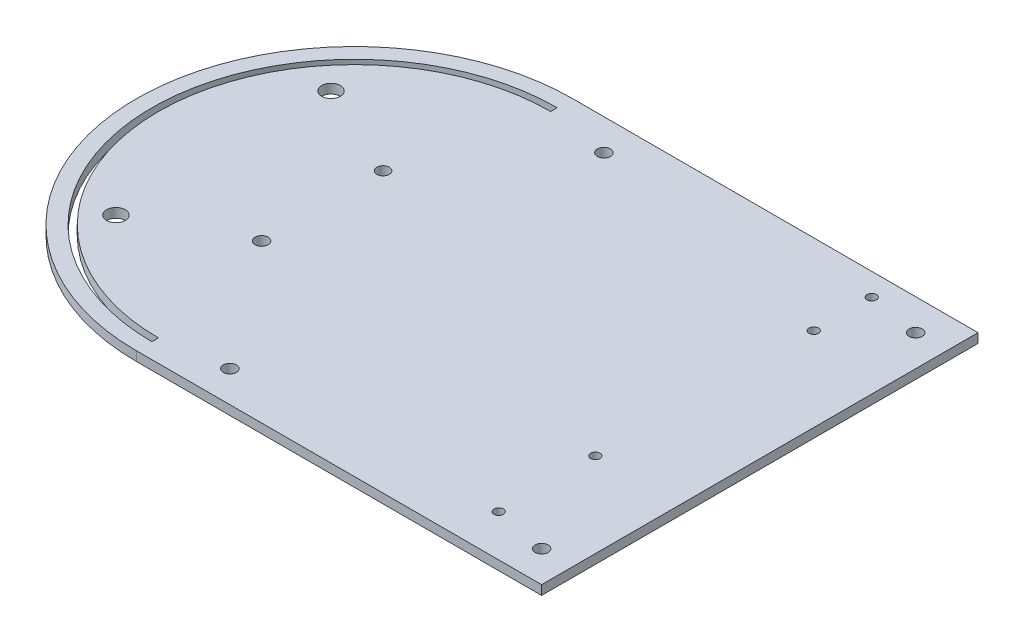
from build123d import *

# Parameters (mm, degrees)
SKETCH1_R           = 2.1
SKETCH1_R_2         = 1.5
SKETCH1_R_3         = 2
SKETCH1_R_4         = 3
BOSS_EXTRUDE1_DEPTH = 3


with BuildPart() as part:
    # Sketch1 → Boss-Extrude1 (new body)
    with BuildSketch(Plane(origin=(0, 0, 0), x_dir=(1, 0, 0), z_dir=(0, 1, 0))):
        with BuildLine():
            Line((65, -70), (-65, -70))
            ThreePointArc((-65, -70), (-135, 0), (-65, 70))
            Line((-65, 70), (65, 70))
            Line((65, 70), (65, -70))
        make_face()
        with Locations((-45, -60)):
            Circle(SKETCH1_R, mode=Mode.SUBTRACT)
        with Locations((-45, 60)):
            Circle(SKETCH1_R, mode=Mode.SUBTRACT)
        with Locations((55, -60)):
            Circle(SKETCH1_R, mode=Mode.SUBTRACT)
        with Locations((55, 60)):
            Circle(SKETCH1_R, mode=Mode.SUBTRACT)
        with Locations((37.841964001, -25.6)):
            Circle(SKETCH1_R_2, mode=Mode.SUBTRACT)
        with Locations((37.841964001, -56.6)):
            Circle(SKETCH1_R_2, mode=Mode.SUBTRACT)
        with Locations((38.099271459, 44.2)):
            Circle(SKETCH1_R_2, mode=Mode.SUBTRACT)
        with Locations((38.099271459, 62.8)):
            Circle(SKETCH1_R_2, mode=Mode.SUBTRACT)
        with Locations((-75.400632029, -19.426149967)):
            Circle(SKETCH1_R, mode=Mode.SUBTRACT)
        with Locations((-75.399684811, 19.552626294)):
            Circle(SKETCH1_R_3, mode=Mode.SUBTRACT)
        with Locations((-105.935731265, 33.388623858)):
            Circle(SKETCH1_R_4, mode=Mode.SUBTRACT)
        with Locations((-105.935731265, -35.611376142)):
            Circle(SKETCH1_R_4, mode=Mode.SUBTRACT)
        with BuildLine():
            Line((-65, 65), (-65, 62.9))
            ThreePointArc((-65, 62.9), (-127.9, 0), (-65, -62.9))
            Line((-65, -62.9), (-65, -65))
            ThreePointArc((-65, -65), (-130, 0), (-65, 65))
        make_face(mode=Mode.SUBTRACT)
    extrude(amount=BOSS_EXTRUDE1_DEPTH)


solid = part.part
